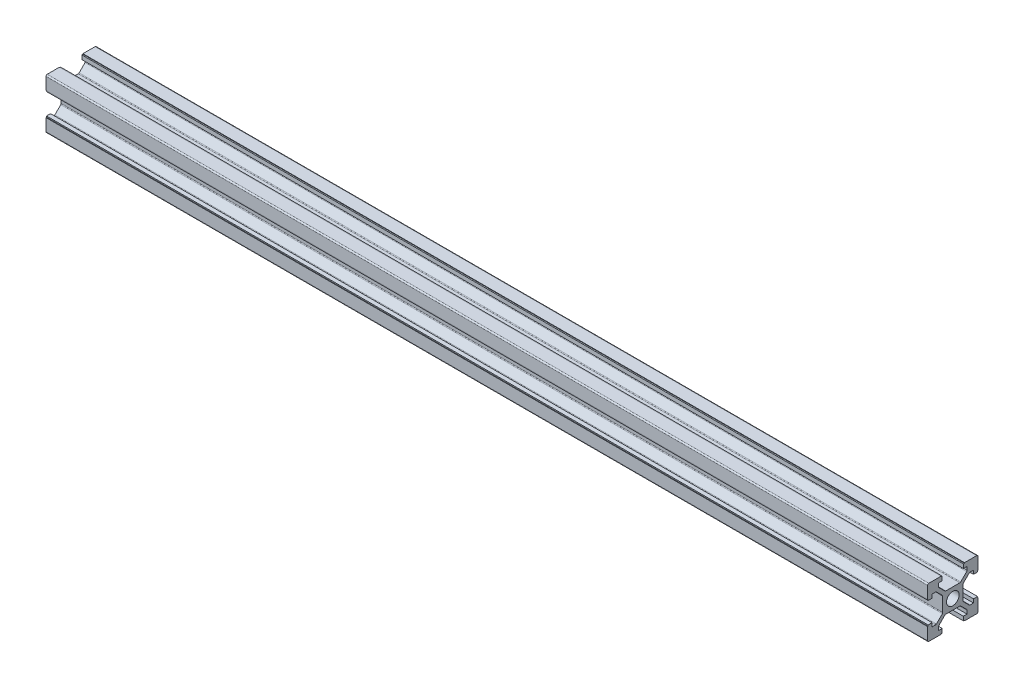
from build123d import *

# Parameters (mm, degrees)
IZIM1_R             = 2.5
BOSS_EXTRUDE1_DEPTH = 350


with BuildPart() as part:
    # Çizim1 → Boss-Extrude1 (new body)
    with BuildSketch(Plane(origin=(0, 0, 0), x_dir=(0, 0, -1), z_dir=(1, 0, 0))):
        with BuildLine():
            Line((-9.5, 10), (-4.65, 10))
            Line((-4.65, 10), (-4.65, 9.8))
            Line((-4.65, 9.8), (-4.2, 9.8))
            Line((-4.2, 9.8), (-4.2, 8.2))
            Line((-4.2, 8.2), (-5.65, 8.2))
            Line((-5.65, 8.2), (-5.65, 6.857106781))
            ThreePointArc((-5.65, 6.857106781), (-5.611939766, 6.665765065), (-5.503553391, 6.503553391))
            Line((-5.503553391, 6.503553391), (-3.146446609, 4.146446609))
            ThreePointArc((-3.146446609, 4.146446609), (-2.984234935, 4.038060234), (-2.792893219, 4))
            Line((-2.792893219, 4), (2.792893219, 4))
            ThreePointArc((2.792893219, 4), (2.984234935, 4.038060234), (3.146446609, 4.146446609))
            Line((3.146446609, 4.146446609), (5.503553391, 6.503553391))
            ThreePointArc((5.503553391, 6.503553391), (5.611939766, 6.665765065), (5.65, 6.857106781))
            Line((5.65, 6.857106781), (5.65, 8.2))
            Line((5.65, 8.2), (4.2, 8.2))
            Line((4.2, 8.2), (4.2, 9.8))
            Line((4.2, 9.8), (4.65, 9.8))
            Line((4.65, 9.8), (4.65, 10))
            Line((4.65, 10), (9.5, 10))
            ThreePointArc((9.5, 10), (9.853553391, 9.853553391), (10, 9.5))
            Line((10, 9.5), (10, 4.65))
            Line((10, 4.65), (9.8, 4.65))
            Line((9.8, 4.65), (9.8, 4.2))
            Line((9.8, 4.2), (8.2, 4.2))
            Line((8.2, 4.2), (8.2, 5.65))
            Line((8.2, 5.65), (6.857106781, 5.65))
            ThreePointArc((6.857106781, 5.65), (6.665765065, 5.611939766), (6.503553391, 5.503553391))
            Line((6.503553391, 5.503553391), (4.146446609, 3.146446609))
            ThreePointArc((4.146446609, 3.146446609), (4.038060234, 2.984234935), (4, 2.792893219))
            Line((4, 2.792893219), (4, -2.792893219))
            ThreePointArc((4, -2.792893219), (4.038060234, -2.984234935), (4.146446609, -3.146446609))
            Line((4.146446609, -3.146446609), (6.503553391, -5.503553391))
            ThreePointArc((6.503553391, -5.503553391), (6.665765065, -5.611939766), (6.857106781, -5.65))
            Line((6.857106781, -5.65), (8.2, -5.65))
            Line((8.2, -5.65), (8.2, -4.2))
            Line((8.2, -4.2), (9.8, -4.2))
            Line((9.8, -4.2), (9.8, -4.65))
            Line((9.8, -4.65), (10, -4.65))
            Line((10, -4.65), (10, -9.5))
            ThreePointArc((10, -9.5), (9.853553391, -9.853553391), (9.5, -10))
            Line((9.5, -10), (4.65, -10))
            Line((4.65, -10), (4.65, -9.8))
            Line((4.65, -9.8), (4.2, -9.8))
            Line((4.2, -9.8), (4.2, -8.2))
            Line((4.2, -8.2), (5.65, -8.2))
            Line((5.65, -8.2), (5.65, -6.857106781))
            ThreePointArc((5.65, -6.857106781), (5.611939766, -6.665765065), (5.503553391, -6.503553391))
            Line((5.503553391, -6.503553391), (3.146446609, -4.146446609))
            ThreePointArc((3.146446609, -4.146446609), (2.984234935, -4.038060234), (2.792893219, -4))
            Line((2.792893219, -4), (-2.792893219, -4))
            ThreePointArc((-2.792893219, -4), (-2.984234935, -4.038060234), (-3.146446609, -4.146446609))
            Line((-3.146446609, -4.146446609), (-5.503553391, -6.503553391))
            ThreePointArc((-5.503553391, -6.503553391), (-5.611939766, -6.665765065), (-5.65, -6.857106781))
            Line((-5.65, -6.857106781), (-5.65, -8.2))
            Line((-5.65, -8.2), (-4.2, -8.2))
            Line((-4.2, -8.2), (-4.2, -9.8))
            Line((-4.2, -9.8), (-4.65, -9.8))
            Line((-4.65, -9.8), (-4.65, -10))
            Line((-4.65, -10), (-9.5, -10))
            ThreePointArc((-9.5, -10), (-9.853553391, -9.853553391), (-10, -9.5))
            Line((-10, -9.5), (-10, -4.65))
            Line((-10, -4.65), (-9.8, -4.65))
            Line((-9.8, -4.65), (-9.8, -4.2))
            Line((-9.8, -4.2), (-8.2, -4.2))
            Line((-8.2, -4.2), (-8.2, -5.65))
            Line((-8.2, -5.65), (-6.857106781, -5.65))
            ThreePointArc((-6.857106781, -5.65), (-6.665765065, -5.611939766), (-6.503553391, -5.503553391))
            Line((-6.503553391, -5.503553391), (-4.146446609, -3.146446609))
            ThreePointArc((-4.146446609, -3.146446609), (-4.038060234, -2.984234935), (-4, -2.792893219))
            Line((-4, -2.792893219), (-4, 2.792893219))
            ThreePointArc((-4, 2.792893219), (-4.038060234, 2.984234935), (-4.146446609, 3.146446609))
            Line((-4.146446609, 3.146446609), (-6.503553391, 5.503553391))
            ThreePointArc((-6.503553391, 5.503553391), (-6.665765065, 5.611939766), (-6.857106781, 5.65))
            Line((-6.857106781, 5.65), (-8.2, 5.65))
            Line((-8.2, 5.65), (-8.2, 4.2))
            Line((-8.2, 4.2), (-9.8, 4.2))
            Line((-9.8, 4.2), (-9.8, 4.65))
            Line((-9.8, 4.65), (-10, 4.65))
            Line((-10, 4.65), (-10, 9.5))
            ThreePointArc((-10, 9.5), (-9.853553391, 9.853553391), (-9.5, 10))
        make_face()
        Circle(IZIM1_R, mode=Mode.SUBTRACT)
    extrude(amount=BOSS_EXTRUDE1_DEPTH)


solid = part.part
